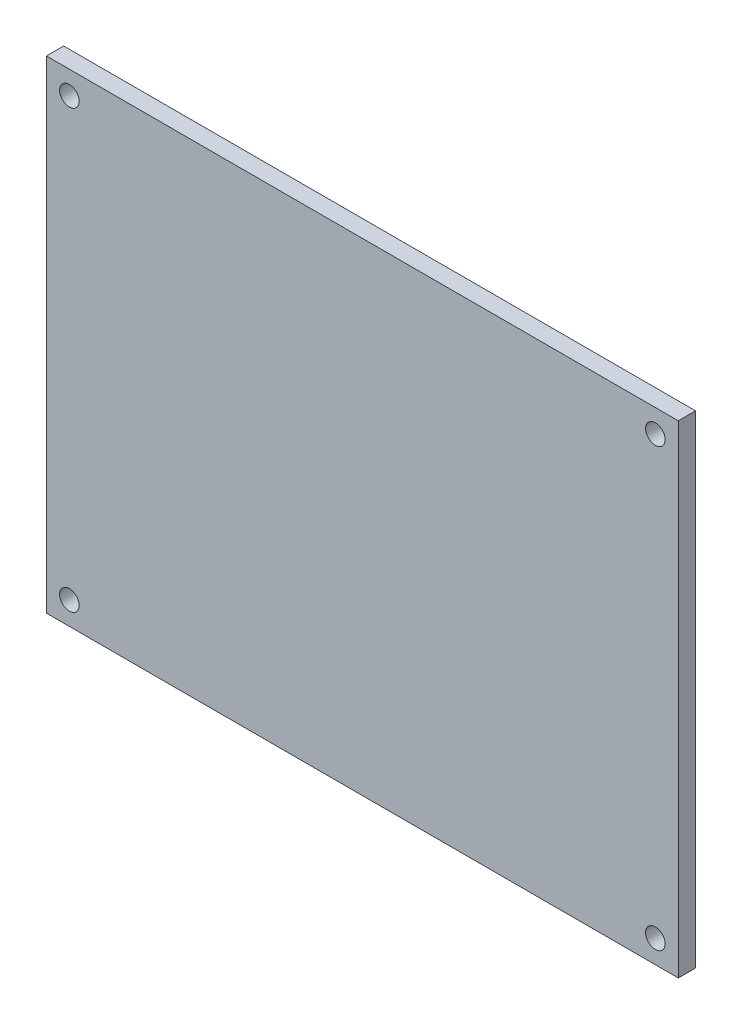
from build123d import *

# Parameters (mm, degrees)
SKETCH_1_W      = 110
SKETCH_1_H      = 84
SKETCH_1_R      = 1.7
EXTRUDE_1_DEPTH = 3


with BuildPart() as part:
    # 草图1 → 凸台-拉伸1 (new body)
    with BuildSketch(Plane.XY):
        with Locations((2.870563674, -6.979123173)):
            Rectangle(SKETCH_1_W, SKETCH_1_H)
        with Locations((-48.129436326, 31.020876827)):
            Circle(SKETCH_1_R, mode=Mode.SUBTRACT)
        with Locations((53.870563674, 31.020876827)):
            Circle(SKETCH_1_R, mode=Mode.SUBTRACT)
        with Locations((53.870563674, -44.979123173)):
            Circle(SKETCH_1_R, mode=Mode.SUBTRACT)
        with Locations((-48.129436326, -44.979123173)):
            Circle(SKETCH_1_R, mode=Mode.SUBTRACT)
    extrude(amount=EXTRUDE_1_DEPTH)


solid = part.part
